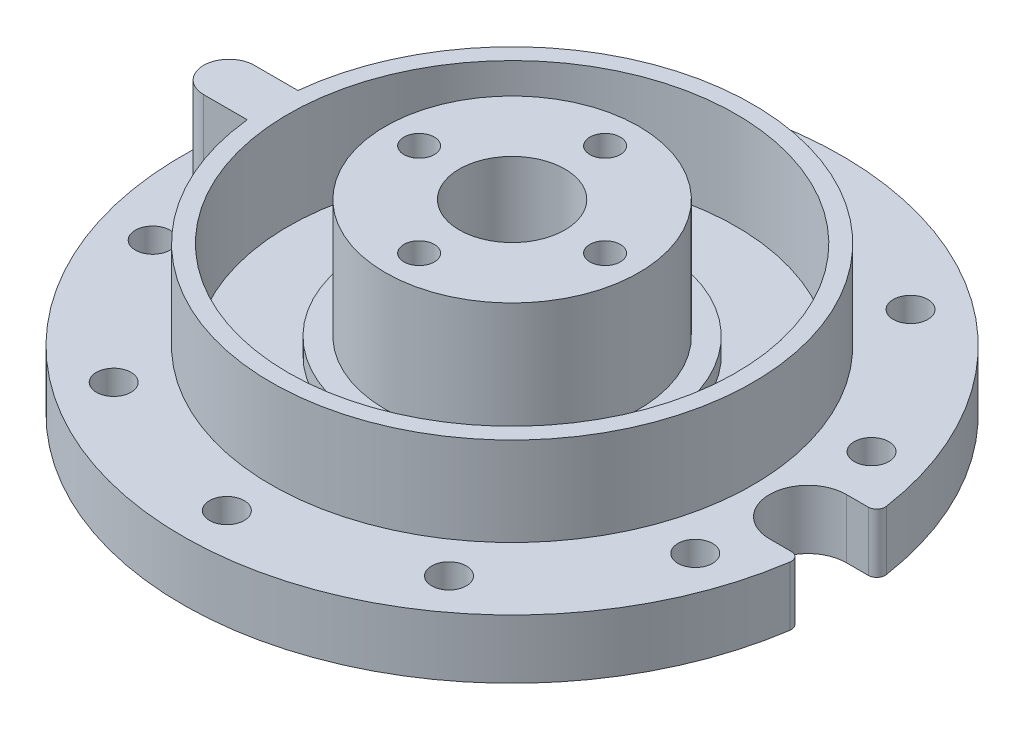
from build123d import *

# Parameters (mm, degrees)
SKETCH1_R                                           = 39
BOSS_EXTRUDE1_DEPTH                                 = 7
SKETCH3_R                                           = 17.5
BOSS_EXTRUDE2_DEPTH                                 = 1
SKETCH4_R                                           = 15
BOSS_EXTRUDE3_DEPTH                                 = 14
SKETCH5_R                                           = 6.25
SKETCH5_R_2                                         = 1.8
CUT_EXTRUDE1_DEPTH                                  = 23
CSK_FOR_M4_COUNTERSUNK_FLAT_HEAD_SCREW1_D           = 3.5
CSK_FOR_M4_COUNTERSUNK_FLAT_HEAD_SCREW1_CSINK_D     = 9.1
CSK_FOR_M4_COUNTERSUNK_FLAT_HEAD_SCREW1_CSINK_ANGLE = 90
SKETCH7_R                                           = 28.5
SKETCH7_R_2                                         = 26.5
BOSS_EXTRUDE4_DEPTH                                 = 10.5
SKETCH8_R                                           = 26.5
SKETCH8_R_2                                         = 17.5
CUT_EXTRUDE2_DEPTH                                  = 1
SKETCH9_R                                           = 2.05
CUT_EXTRUDE3_DEPTH                                  = 8.0000001
BOSS_EXTRUDE5_DEPTH                                 = 10.5
CUT_EXTRUDE4_DEPTH                                  = 8.0000001
FILLET1_R                                           = 1


with BuildPart() as part:
    # Sketch1 → Boss-Extrude1 (new body)
    with BuildSketch(Plane(origin=(0, 0, 0), x_dir=(1, 0, 0), z_dir=(0, 1, 0))):
        Circle(SKETCH1_R)
    extrude(amount=BOSS_EXTRUDE1_DEPTH)

    # Sketch3 → Boss-Extrude2 (add)
    with BuildSketch(Plane(origin=(0, 7, 0), x_dir=(1, 0, 0), z_dir=(0, 1, 0))):
        Circle(SKETCH3_R)
    extrude(amount=BOSS_EXTRUDE2_DEPTH)

    # Sketch4 → Boss-Extrude3 (add)
    with BuildSketch(Plane(origin=(0, 8, 0), x_dir=(1, 0, 0), z_dir=(0, 1, 0))):
        Circle(SKETCH4_R)
    extrude(amount=BOSS_EXTRUDE3_DEPTH)

    # Sketch5 → Cut-Extrude1 (cut, through all)
    with BuildSketch(Plane(origin=(0, 22, 0), x_dir=(1, 0, 0), z_dir=(0, 1, 0))):
        Circle(SKETCH5_R)
        with Locations((0, 11)):
            Circle(SKETCH5_R_2)
        with Locations((11, 0)):
            Circle(SKETCH5_R_2)
        with Locations((0, -11)):
            Circle(SKETCH5_R_2)
        with Locations((-11, 0)):
            Circle(SKETCH5_R_2)
    extrude(amount=-CUT_EXTRUDE1_DEPTH, mode=Mode.SUBTRACT)

    # CSK for M4 Countersunk Flat Head Screw1 (through all)
    with Locations(Plane(origin=(11, 0, 0), x_dir=(0, 0, -1), z_dir=(0, -1, 0))):
        with Locations((0, 0), (11, -11), (0, -22), (-11, -11)):
            CounterSinkHole(CSK_FOR_M4_COUNTERSUNK_FLAT_HEAD_SCREW1_D / 2, CSK_FOR_M4_COUNTERSUNK_FLAT_HEAD_SCREW1_CSINK_D / 2, counter_sink_angle=CSK_FOR_M4_COUNTERSUNK_FLAT_HEAD_SCREW1_CSINK_ANGLE)

    # Sketch7 → Boss-Extrude4 (add)
    with BuildSketch(Plane(origin=(0, 7, 0), x_dir=(1, 0, 0), z_dir=(0, 1, 0))):
        Circle(SKETCH7_R)
        Circle(SKETCH7_R_2, mode=Mode.SUBTRACT)
    extrude(amount=BOSS_EXTRUDE4_DEPTH)

    # Sketch8 → Cut-Extrude2 (cut)
    with BuildSketch(Plane(origin=(0, 7, 0), x_dir=(1, 0, 0), z_dir=(0, 1, 0))):
        Circle(SKETCH8_R)
        Circle(SKETCH8_R_2, mode=Mode.SUBTRACT)
    extrude(amount=-CUT_EXTRUDE2_DEPTH, mode=Mode.SUBTRACT)

    # Sketch9 → Cut-Extrude3 (cut, through all)
    with BuildSketch(Plane(origin=(0, 7, 0), x_dir=(1, 0, 0), z_dir=(0, 1, 0))):
        with Locations((0, 33.75)):
            Circle(SKETCH9_R)
        with Locations((19.837752265, 27.30432356)):
            Circle(SKETCH9_R)
        with Locations((32.098157425, 10.42932356)):
            Circle(SKETCH9_R)
        with Locations((32.098157425, -10.42932356)):
            Circle(SKETCH9_R)
        with Locations((19.837752265, -27.30432356)):
            Circle(SKETCH9_R)
        with Locations((0, -33.75)):
            Circle(SKETCH9_R)
        with Locations((-19.837752265, -27.30432356)):
            Circle(SKETCH9_R)
        with Locations((-32.098157425, -10.42932356)):
            Circle(SKETCH9_R)
        with Locations((-32.098157425, 10.42932356)):
            Circle(SKETCH9_R)
        with Locations((-19.837752265, 27.30432356)):
            Circle(SKETCH9_R)
    extrude(amount=-CUT_EXTRUDE3_DEPTH, mode=Mode.SUBTRACT)

    # Sketch10 → Boss-Extrude5 (add)
    with BuildSketch(Plane(origin=(0, 7, 0), x_dir=(1, 0, 0), z_dir=(0, 1, 0))):
        with BuildLine():
            Line((-33.5, 3), (-28.341665442, 3))
            ThreePointArc((-28.341665442, 3), (-28.5, 0), (-28.341665442, -3))
            Line((-28.341665442, -3), (-33.5, -3))
            ThreePointArc((-33.5, -3), (-36.5, 0), (-33.5, 3))
        make_face()
    extrude(amount=BOSS_EXTRUDE5_DEPTH)

    # Sketch11 → Cut-Extrude4 (cut, through all)
    with BuildSketch(Plane(origin=(0, 7, 0), x_dir=(1, 0, 0), z_dir=(0, 1, 0))):
        with BuildLine():
            Line((35, 4.55), (38.73367398, 4.55))
            ThreePointArc((38.73367398, 4.55), (39, 0), (38.73367398, -4.55))
            Line((38.73367398, -4.55), (35, -4.55))
            ThreePointArc((35, -4.55), (30.45, 0), (35, 4.55))
        make_face()
    extrude(amount=-CUT_EXTRUDE4_DEPTH, mode=Mode.SUBTRACT)

    # Fillet1
    fillet1_edges = [part.edges().sort_by_distance(p)[0] for p in [
        (38.73367398, 3.5, -4.55),
        (38.73367398, 3.5, 4.55),
    ]]
    fillet(fillet1_edges, radius=FILLET1_R)


solid = part.part
